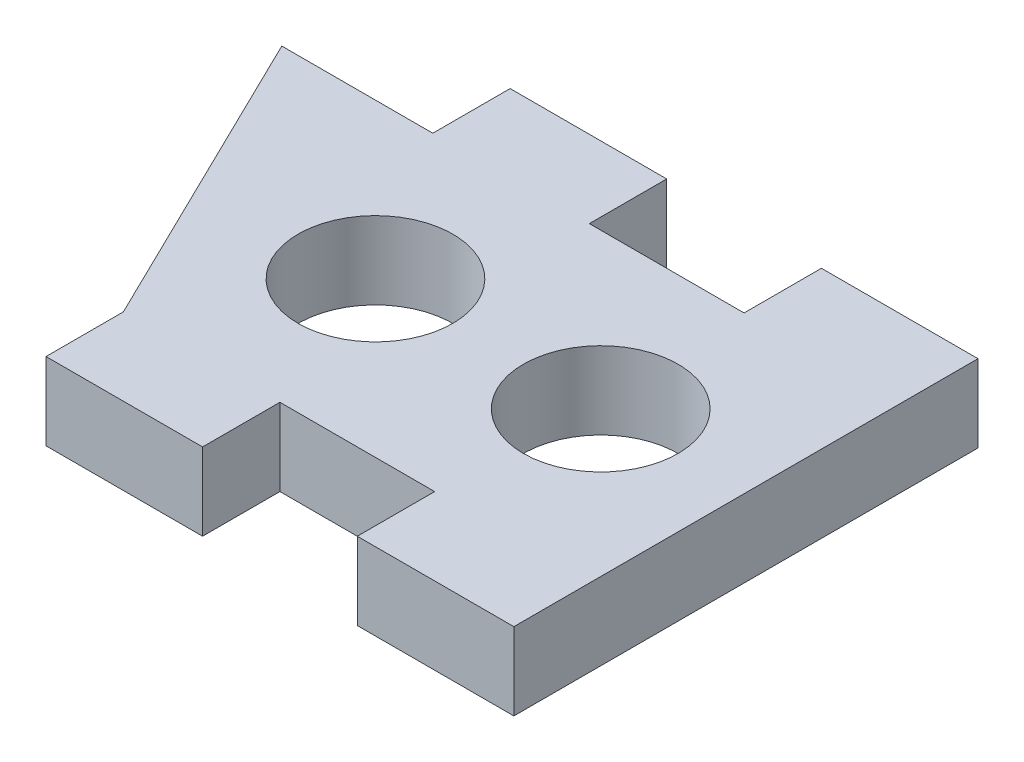
from build123d import *

# Parameters (mm, degrees)
SKETCH1_W           = 25.4
SKETCH1_H           = 12.7
BOSS_EXTRUDE1_DEPTH = 3.175
SKETCH2_W           = 6.4262
SKETCH2_H           = 3.175
BOSS_EXTRUDE2_DEPTH = 3.175
CUT_EXTRUDE1_DEPTH  = 3.175
SKETCH4_R           = 3.175
CUT_EXTRUDE2_DEPTH  = 4.175


with BuildPart() as part:
    # Sketch1 → Boss-Extrude1 (new body)
    with BuildSketch(Plane(origin=(0, 0, 0), x_dir=(1, 0, 0), z_dir=(0, 1, 0))):
        Rectangle(SKETCH1_W, SKETCH1_H)
    extrude(amount=BOSS_EXTRUDE1_DEPTH)

    # Sketch2 → Boss-Extrude2 (add)
    with BuildSketch(Plane.XY.offset(6.35)):
        with Locations((9.4869, 1.5875)):
            Rectangle(SKETCH2_W, SKETCH2_H)
        with Locations((-3.2893, 1.5875)):
            Rectangle(SKETCH2_W, SKETCH2_H)
    boss_extrude2 = extrude(amount=BOSS_EXTRUDE2_DEPTH)

    # Mirror1: Boss-Extrude2 across plane
    add(boss_extrude2.mirror(Plane.XY))

    # Sketch3 → Cut-Extrude1 (cut)
    with BuildSketch(Plane(origin=(0, 3.175, 0), x_dir=(1, 0, 0), z_dir=(0, 1, 0))):
        Polygon((-6.5024, -6.35), (-12.7, 6.35), (-12.7, -6.35), align=None)
    extrude(amount=-CUT_EXTRUDE1_DEPTH, mode=Mode.SUBTRACT)

    # Sketch4 → Cut-Extrude2 (cut, through all)
    with BuildSketch(Plane(origin=(0, 3.175, 0), x_dir=(1, 0, 0), z_dir=(0, 1, 0))):
        with Locations((-2.505931508, 0)):
            Circle(SKETCH4_R)
        with Locations((6.741308704, 0)):
            Circle(SKETCH4_R)
    extrude(amount=-CUT_EXTRUDE2_DEPTH, mode=Mode.SUBTRACT)


solid = part.part
